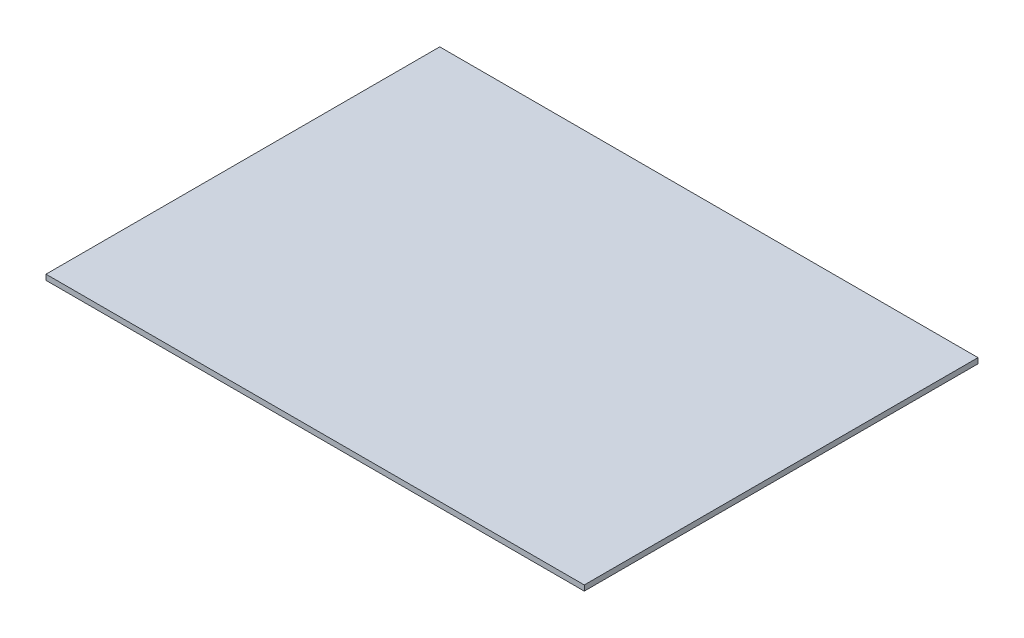
from build123d import *

# Parameters (mm, degrees)
SKETCH1_W           = 200
SKETCH1_H           = 146.29309458
BOSS_EXTRUDE2_DEPTH = 2


with BuildPart() as part:
    # Sketch1 → Boss-Extrude2 (new body)
    with BuildSketch(Plane(origin=(0, 0, 0), x_dir=(1, 0, 0), z_dir=(0, 1, 0))):
        with Locations((100, 73.14654729)):
            Rectangle(SKETCH1_W, SKETCH1_H)
    extrude(amount=BOSS_EXTRUDE2_DEPTH)


solid = part.part
